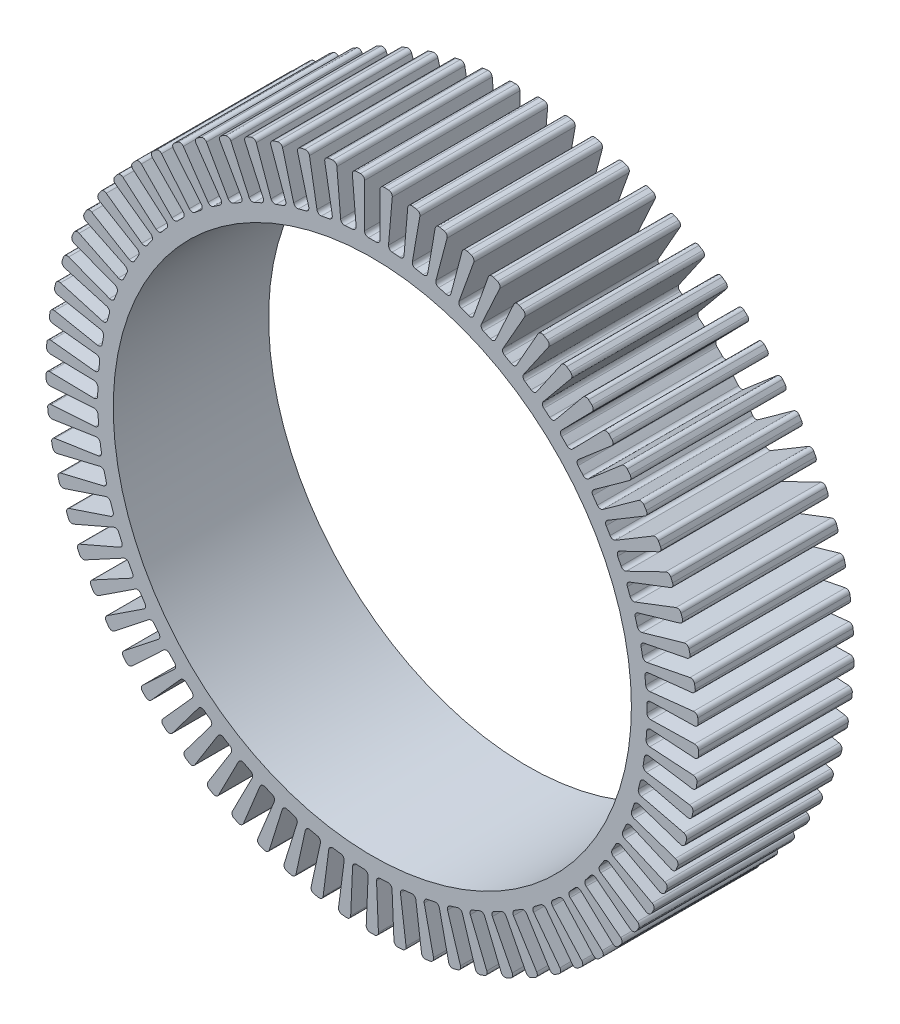
from build123d import *

# Parameters (mm, degrees)
SKETCH_1_R               = 42
SKETCH_1_R_2             = 33.35
EXTRUDE_1_DEPTH          = 10
CUT_EXTRUDE_1_DEPTH      = 20
PATTERN_CIRCULAR_1_COUNT = 73
FILLET_1_R               = 0.5


with BuildPart() as part:
    # 草图1 → 凸台-拉伸1 (new body, symmetric)
    with BuildSketch(Plane.XY):
        Circle(SKETCH_1_R)
        Circle(SKETCH_1_R_2, mode=Mode.SUBTRACT)
    extrude(amount=EXTRUDE_1_DEPTH, both=True)

    # 草图2 → 切除-拉伸1 (cut)
    with BuildSketch(Plane.XY.offset(10)):
        with BuildLine():
            Line((-1, 41.98809355), (-1, 35.335852898))
            ThreePointArc((-1, 35.335852898), (0, 35.35), (1, 35.335852898))
            Line((1, 35.335852898), (1, 41.98809355))
            ThreePointArc((1, 41.98809355), (0, 42), (-1, 41.98809355))
        make_face()
    cut_extrude_1 = extrude(amount=-CUT_EXTRUDE_1_DEPTH, mode=Mode.SUBTRACT)

    # 阵列(圆周)1: 切除-拉伸1 ×73 about axis
    pattern_circular_1_axis = Axis((0, 0, 0), (0, 0, 1))
    for i in range(1, PATTERN_CIRCULAR_1_COUNT):
        add(cut_extrude_1.rotate(pattern_circular_1_axis, i * 360 / PATTERN_CIRCULAR_1_COUNT), mode=Mode.SUBTRACT)

    # 圆角1
    fillet_1_edges = [part.edges().sort_by_distance(p)[0] for p in [
        (-1, 41.98809355, 0),
        (1, 41.98809355, 0),
        (1, 35.335852898, 0),
        (-1, 35.335852898, 0),
        (26.059826822, -32.937598972, 0),
        (24.462268076, -34.140847098, 0),
        (20.460120025, -28.827174481, 0),
        (22.057678771, -27.623926355, 0),
        (28.794831968, -30.575441974, 0),
        (27.306624088, -31.911569703, 0),
        (22.862502492, -26.961611224, 0),
        (24.350710372, -25.625483496, 0),
        (20.032680474, -36.914654448, 0),
        (18.252625321, -37.826467835, 0),
        (15.21982428, -31.905790209, 0),
        (16.999879433, -30.993976822, 0),
        (23.131883835, -35.05589751, 0),
        (21.436801989, -36.117357606, 0),
        (17.906257987, -30.479311424, 0),
        (19.601339833, -29.417851328, 0),
        (35.647760189, -22.208943998, 0),
        (34.550074273, -23.880794956, 0),
        (28.989296816, -20.229759517, 0),
        (30.086982732, -18.557908558, 0),
        (37.424985818, -19.062277842, 0),
        (36.475083674, -20.82230225, 0),
        (30.621030716, -17.66281342, 0),
        (31.57093286, -15.902789012, 0),
        (31.316650253, -27.986915102, 0),
        (29.94881141, -29.44603021, 0),
        (25.09561899, -24.89643363, 0),
        (26.463457833, -23.437318522, 0),
        (33.606611016, -25.191182902, 0),
        (32.36926821, -26.762482612, 0),
        (27.142936305, -22.646931553, 0),
        (28.380279111, -21.075631843, 0),
        (6.397567839, -41.509891902, 0),
        (4.414213199, -41.767388257, 0),
        (3.557749339, -35.170512075, 0),
        (5.541103979, -34.91301572, 0),
        (9.942274665, -40.806263912, 0),
        (7.98839768, -41.233305743, 0),
        (6.568005166, -34.734475786, 0),
        (8.521882151, -34.307433955, 0),
        (16.785162155, -38.5001082, 0),
        (14.933312601, -39.255524131, 0),
        (12.42070832, -33.096049686, 0),
        (14.272557874, -32.340633756, 0),
        (13.413372368, -39.800520621, 0),
        (11.503438858, -40.39394626, 0),
        (9.52963378, -34.041277591, 0),
        (11.43956729, -33.447851952, 0),
        (2.805495659, -41.906195176, 0),
        (0.807347429, -41.992239642, 0),
        (0.521153182, -35.346158198, 0),
        (2.519301412, -35.260113732, 0),
        (-0.807347429, -41.992239642, 0),
        (-2.805495659, -41.906195176, 0),
        (-2.519301412, -35.260113732, 0),
        (-0.521153182, -35.346158198, 0),
        (-4.414213199, -41.767388257, 0),
        (-6.397567839, -41.509891902, 0),
        (-5.541103979, -34.91301572, 0),
        (-3.557749339, -35.170512075, 0),
        (-7.98839768, -41.233305743, 0),
        (-9.942274665, -40.806263912, 0),
        (-8.521882151, -34.307433955, 0),
        (-6.568005166, -34.734475786, 0),
        (37.337133884, 19.233783646, 0),
        (38.210436348, 17.434521907, 0),
        (32.225875304, 14.52981283, 0),
        (31.35257284, 16.32907457, 0),
        (35.545490006, 22.372262743, 0),
        (36.57023283, 20.654734827, 0),
        (30.857528316, 17.24631689, 0),
        (29.832785491, 18.963844806, 0),
        (40.079910306, 12.553915319, 0),
        (40.632104252, 10.631655752, 0),
        (34.238437631, 8.794992243, 0),
        (33.686243685, 10.717251811, 0),
        (38.852346686, 15.952904344, 0),
        (39.567743164, 14.085229886, 0),
        (33.355633187, 11.70573512, 0),
        (32.640236709, 13.573409578, 0),
        (28.654248285, 30.707231318, 0),
        (30.083595057, 29.308314664, 0),
        (25.430629939, 24.554135312, 0),
        (24.001283167, 25.953051966, 0),
        (25.90843431, 33.056815206, 0),
        (27.452747479, 31.785950605, 0),
        (23.225698895, 26.649379183, 0),
        (21.681385726, 27.920243785, 0),
        (33.490679756, 25.345105435, 0),
        (34.659276103, 23.722027317, 0),
        (29.260722983, 19.835135253, 0),
        (28.092126636, 21.458213371, 0),
        (31.18791623, 28.130301833, 0),
        (32.491714222, 26.613690216, 0),
        (27.447281496, 22.277101214, 0),
        (26.143483504, 23.793712831, 0),
        (41.010736293, 9.061981498, 0),
        (41.395639457, 7.099368557, 0),
        (34.867752663, 5.81913432, 0),
        (34.482849499, 7.781747261, 0),
        (41.637933138, 5.502955936, 0),
        (41.852695831, 3.514520122, 0),
        (35.238919053, 2.800193563, 0),
        (35.024156359, 4.788629377, 0),
        (41.956857292, 1.903188414, 0),
        (41.999889487, -0.09634859, 0),
        (35.349188815, -0.239478848, 0),
        (35.30615662, 1.760058156, 0),
        (41.965147555, -1.710669649, 0),
        (41.836130657, -3.706503971, 0),
        (35.197745551, -3.277378241, 0),
        (35.32676245, -1.28154392, 0),
        (40.13708603, -12.369895919, 0),
        (39.502703453, -14.266619079, 0),
        (33.193973996, -12.156586294, 0),
        (33.828356574, -10.259863134, 0),
        (38.925129946, -15.77448125, 0),
        (38.130044317, -17.609648502, 0),
        (32.026057217, -14.965098032, 0),
        (32.821142846, -13.12993078, 0),
        (41.051881172, -8.873728205, 0),
        (40.582898393, -10.817964599, 0),
        (34.116134206, -9.258071444, 0),
        (34.585116985, -7.313835051, 0),
        (41.662742548, -5.311862513, 0),
        (41.362631752, -7.289217694, 0),
        (34.785710493, -6.291013073, 0),
        (35.08582129, -4.313657892, 0),
        (-38.130044317, -17.609648502, 0),
        (-38.925129946, -15.77448125, 0),
        (-32.821142846, -13.12993078, 0),
        (-32.026057217, -14.965098032, 0),
        (-39.502703453, -14.266619079, 0),
        (-40.13708603, -12.369895919, 0),
        (-33.828356574, -10.259863134, 0),
        (-33.193973996, -12.156586294, 0),
        (-34.550074273, -23.880794956, 0),
        (-35.647760189, -22.208943998, 0),
        (-30.086982732, -18.557908558, 0),
        (-28.989296816, -20.229759517, 0),
        (-36.475083674, -20.82230225, 0),
        (-37.424985818, -19.062277842, 0),
        (-31.57093286, -15.902789012, 0),
        (-30.621030716, -17.66281342, 0),
        (-40.582898393, -10.817964599, 0),
        (-41.051881172, -8.873728205, 0),
        (-34.585116985, -7.313835051, 0),
        (-34.116134206, -9.258071444, 0),
        (-41.362631752, -7.289217694, 0),
        (-41.662742548, -5.311862513, 0),
        (-35.08582129, -4.313657892, 0),
        (-34.785710493, -6.291013073, 0),
        (-41.836130657, -3.706503971, 0),
        (-41.965147555, -1.710669649, 0),
        (-35.32676245, -1.28154392, 0),
        (-35.197745551, -3.277378241, 0),
        (-41.999889487, -0.09634859, 0),
        (-41.956857292, 1.903188414, 0),
        (-35.30615662, 1.760058156, 0),
        (-35.349188815, -0.239478848, 0),
        (-18.252625321, -37.826467835, 0),
        (-20.032680474, -36.914654448, 0),
        (-16.999879433, -30.993976822, 0),
        (-15.21982428, -31.905790209, 0),
        (-21.436801989, -36.117357606, 0),
        (-23.131883835, -35.05589751, 0),
        (-19.601339833, -29.417851328, 0),
        (-17.906257987, -30.479311424, 0),
        (-11.503438858, -40.39394626, 0),
        (-13.413372368, -39.800520621, 0),
        (-11.43956729, -33.447851952, 0),
        (-9.52963378, -34.041277591, 0),
        (-14.933312601, -39.255524131, 0),
        (-16.785162155, -38.5001082, 0),
        (-14.272557874, -32.340633756, 0),
        (-12.42070832, -33.096049686, 0),
        (-29.94881141, -29.44603021, 0),
        (-31.316650253, -27.986915102, 0),
        (-26.463457833, -23.437318522, 0),
        (-25.09561899, -24.89643363, 0),
        (-32.36926821, -26.762482612, 0),
        (-33.606611016, -25.191182902, 0),
        (-28.380279111, -21.075631843, 0),
        (-27.142936305, -22.646931553, 0),
        (-24.462268076, -34.140847098, 0),
        (-26.059826822, -32.937598972, 0),
        (-22.057678771, -27.623926355, 0),
        (-20.460120025, -28.827174481, 0),
        (-27.306624088, -31.911569703, 0),
        (-28.794831968, -30.575441974, 0),
        (-24.350710372, -25.625483496, 0),
        (-22.862502492, -26.961611224, 0),
        (-24.618649364, 34.028254488, 0),
        (-22.970803353, 35.161658, 0),
        (-19.200966891, 29.680723887, 0),
        (-20.848812903, 28.547320374, 0),
        (-21.602283382, 36.01862508, 0),
        (-19.863104604, 37.006176181, 0),
        (-16.578390816, 31.221458293, 0),
        (-18.317569594, 30.233907193, 0),
        (-30.083595057, 29.308314664, 0),
        (-28.654248285, 30.707231318, 0),
        (-24.001283167, 25.953051966, 0),
        (-25.430629939, 24.554135312, 0),
        (-27.452747479, 31.785950605, 0),
        (-25.90843431, 33.056815206, 0),
        (-21.681385726, 27.920243785, 0),
        (-23.225698895, 26.649379183, 0),
        (-11.688645857, 40.340743152, 0),
        (-9.75495023, 40.851449742, 0),
        (-8.05627866, 34.419745411, 0),
        (-9.989974287, 33.909038821, 0),
        (-8.177492669, 41.196220866, 0),
        (-6.207052456, 41.538807154, 0),
        (-5.067569238, 34.984885908, 0),
        (-7.038009452, 34.64229962, 0),
        (-18.425981652, 37.742326374, 0),
        (-16.608346378, 38.57671358, 0),
        (-13.833074134, 32.531039946, 0),
        (-15.650709409, 31.696652741, 0),
        (-15.113260401, 39.186596689, 0),
        (-13.230625766, 39.861642488, 0),
        (-10.985342212, 33.599773161, 0),
        (-12.867976847, 32.924727362, 0),
        (-40.632104252, 10.631655752, 0),
        (-40.079910306, 12.553915319, 0),
        (-33.686243685, 10.717251811, 0),
        (-34.238437631, 8.794992243, 0),
        (-39.567743164, 14.085229886, 0),
        (-38.852346686, 15.952904344, 0),
        (-32.640236709, 13.573409578, 0),
        (-33.355633187, 11.70573512, 0),
        (-41.395639457, 7.099368557, 0),
        (-41.010736293, 9.061981498, 0),
        (-34.482849499, 7.781747261, 0),
        (-34.867752663, 5.81913432, 0),
        (-41.852695831, 3.514520122, 0),
        (-41.637933138, 5.502955936, 0),
        (-35.024156359, 4.788629377, 0),
        (-35.238919053, 2.800193563, 0),
        (-34.659276103, 23.722027317, 0),
        (-33.490679756, 25.345105435, 0),
        (-28.092126636, 21.458213371, 0),
        (-29.260722983, 19.835135253, 0),
        (-32.491714222, 26.613690216, 0),
        (-31.18791623, 28.130301833, 0),
        (-26.143483504, 23.793712831, 0),
        (-27.447281496, 22.277101214, 0),
        (-38.210436348, 17.434521907, 0),
        (-37.337133884, 19.233783646, 0),
        (-31.35257284, 16.32907457, 0),
        (-32.225875304, 14.52981283, 0),
        (-36.57023283, 20.654734827, 0),
        (-35.545490006, 22.372262743, 0),
        (-29.832785491, 18.963844806, 0),
        (-30.857528316, 17.24631689, 0),
        (2.613199836, 41.918625772, 0),
        (4.605796186, 41.746696175, 0),
        (4.033937657, 35.119080953, 0),
        (2.041341308, 35.29101055, 0),
        (9.75495023, 40.851449742, 0),
        (11.688645857, 40.340743152, 0),
        (9.989974287, 33.909038821, 0),
        (8.05627866, 34.419745411, 0),
        (6.207052456, 41.538807154, 0),
        (8.177492669, 41.196220866, 0),
        (7.038009452, 34.64229962, 0),
        (5.067569238, 34.984885908, 0),
        (19.863104604, 37.006176181, 0),
        (21.602283382, 36.01862508, 0),
        (18.317569594, 30.233907193, 0),
        (16.578390816, 31.221458293, 0),
        (22.970803353, 35.161658, 0),
        (24.618649364, 34.028254488, 0),
        (20.848812903, 28.547320374, 0),
        (19.200966891, 29.680723887, 0),
        (13.230625766, 39.861642488, 0),
        (15.113260401, 39.186596689, 0),
        (12.867976847, 32.924727362, 0),
        (10.985342212, 33.599773161, 0),
        (16.608346378, 38.57671358, 0),
        (18.425981652, 37.742326374, 0),
        (15.650709409, 31.696652741, 0),
        (13.833074134, 32.531039946, 0),
        (-4.605796186, 41.746696175, 0),
        (-2.613199836, 41.918625772, 0),
        (-2.041341308, 35.29101055, 0),
        (-4.033937657, 35.119080953, 0),
    ]]
    fillet(fillet_1_edges, radius=FILLET_1_R)


solid = part.part
